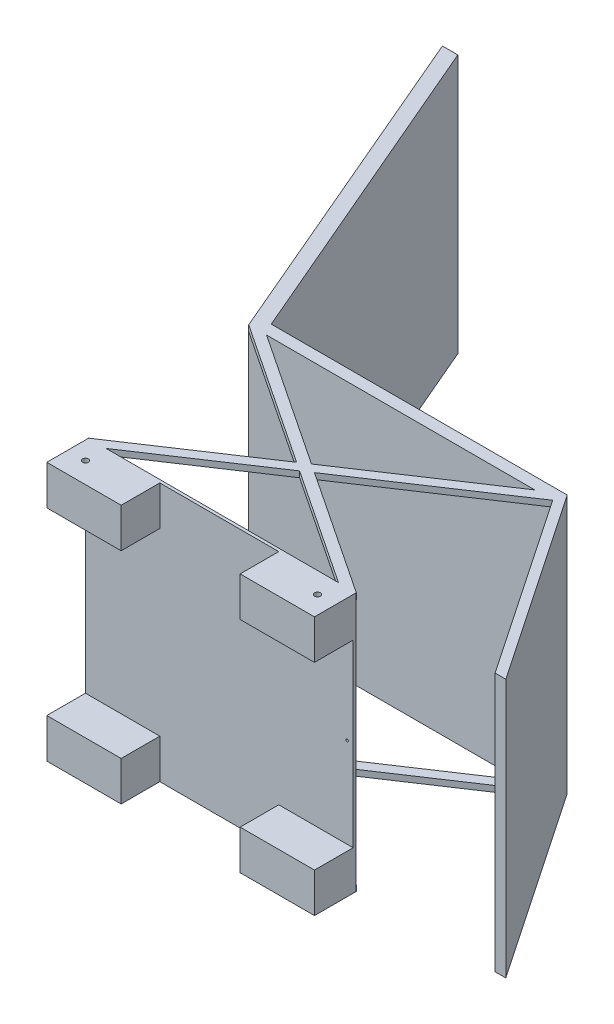
from build123d import *

# Parameters (mm, degrees)
EXTRUDE_1_DEPTH          = 70
CUT_EXTRUDE_1_DEPTH      = 1
CUT_EXTRUDE_1_DEPTH_BACK = 65
SKETCH_4_R               = 2
CUT_EXTRUDE_2_DEPTH      = 10
SKETCH_3_R               = 5
CUT_EXTRUDE_3_DEPTH      = 10
EXTRUDE_2_DEPTH          = 10
EXTRUDE_3_DEPTH          = 435


with BuildPart() as part:
    # 草图1 → 凸台-拉伸1 (new body)
    with BuildSketch(Plane.XY):
        Polygon((225, 0), (225, 217.5), (-225, 217.5), (-225, 0), (-225, -217.5), (225, -217.5), align=None)
    extrude(amount=EXTRUDE_1_DEPTH)

    # 草图2 → 切除-拉伸1 (cut, two sides)
    with BuildSketch(Plane.XY.offset(70)) as cut_extrude_1_sk:
        Polygon((0, 217.5), (-100, 217.5), (-100, 151.164004593), (-225, 151.164004593), (-225, -151.164004593), (-100, -151.164004593), (-100, -217.5), (100, -217.5), (100, -151.164004593), (225, -151.164004593), (225, 151.164004593), (100, 151.164004593), (100, 217.5), align=None)
    extrude(amount=CUT_EXTRUDE_1_DEPTH, mode=Mode.SUBTRACT)
    extrude(cut_extrude_1_sk.sketch, amount=-CUT_EXTRUDE_1_DEPTH_BACK, mode=Mode.SUBTRACT)

    # 草图4 → 切除-拉伸2 (cut)
    with BuildSketch(Plane.XY.offset(5)):
        with Locations((215, 0)):
            Circle(SKETCH_4_R)
    extrude(amount=-CUT_EXTRUDE_2_DEPTH, mode=Mode.SUBTRACT)

    # 草图3 → 切除-拉伸3 (cut)
    with BuildSketch(Plane(origin=(0, 217.5, 0), x_dir=(1, 0, 0), z_dir=(0, 1, 0))):
        with Locations((-195, -35)):
            Circle(SKETCH_3_R)
        with Locations((195, -35)):
            Circle(SKETCH_3_R)
    cut_extrude_3 = extrude(amount=-CUT_EXTRUDE_3_DEPTH, mode=Mode.SUBTRACT)

    # 镜向1: 切除-拉伸3 across plane
    add(cut_extrude_3.mirror(Plane.ZX), mode=Mode.SUBTRACT)

    # 草图6 → 凸台-拉伸2 (add)
    with BuildSketch(Plane(origin=(0, -217.5, 0), x_dir=(-1, 0, 0), z_dir=(0, -1, 0))):
        Polygon((-15.031554005, 140), (-225.473310071, 0), (-225, 0), (-195.410202062, 0), (0, 130), (195.410202062, 0), (225, 0), (225.473310071, 0), (15.031554005, 140), (255.536418081, 300), (225.473310071, 300), (0, 150), (-225.473310071, 300), (-255.536418081, 300), align=None)
    extrude_2 = extrude(amount=-EXTRUDE_2_DEPTH)

    # 镜向2: 凸台-拉伸2 across plane
    add(extrude_2.mirror(Plane.ZX))

    # 草图7 → 凸台-拉伸3 (add)
    with BuildSketch(Plane(origin=(0, 217.5, 0), x_dir=(1, 0, 0), z_dir=(0, 1, 0))):
        Polygon((-255.536418081, 300), (255.536418081, 300), (458.675595133, 0), (476.639391287, 0), (260.073177672, 319.829316172), (-237.490096329, 319.829316172), (-472.660078337, 868.671562843), (-498.536821512, 868.671562843), align=None)
    extrude(amount=-EXTRUDE_3_DEPTH)


solid = part.part
